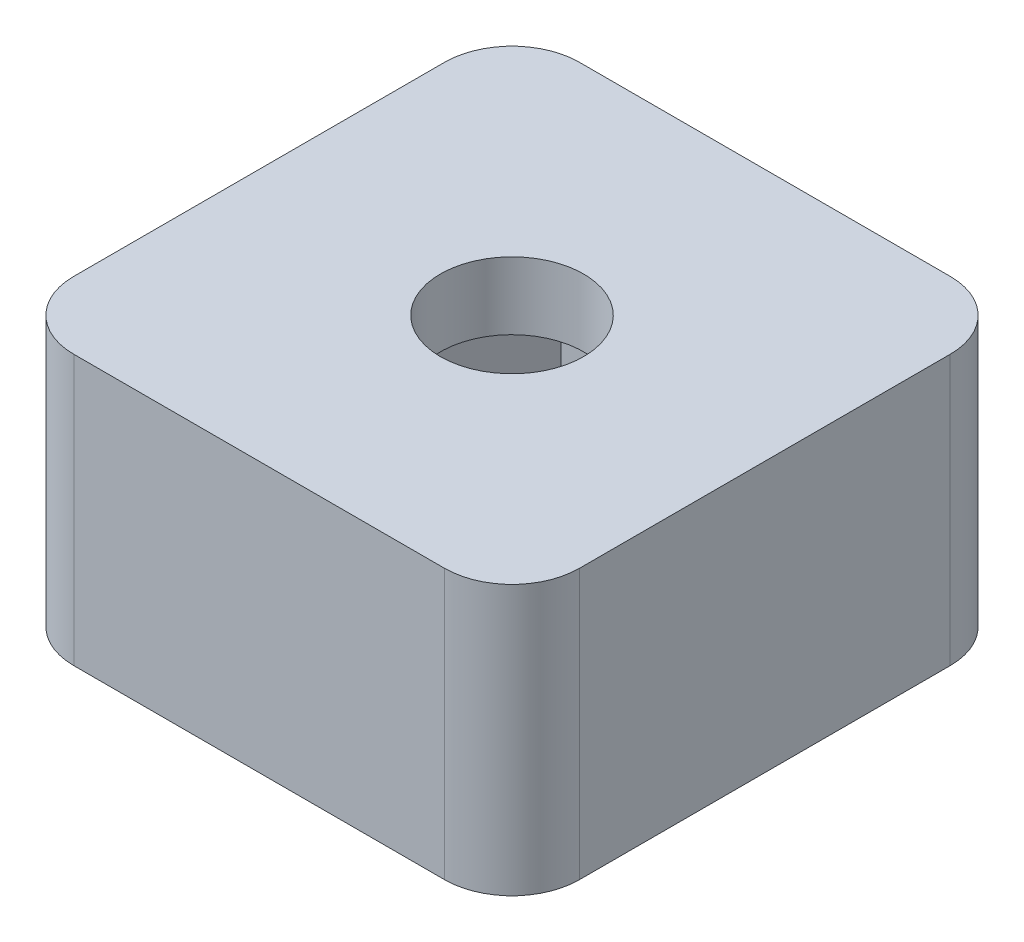
from build123d import *

# Parameters (mm, degrees)
SKETCH1_W           = 15
SKETCH1_H           = 15
BOSS_EXTRUDE1_DEPTH = 8
SKETCH3_R           = 2.125
CUT_EXTRUDE3_DEPTH  = 9
CUT_EXTRUDE2_DEPTH  = 6
FILLET1_R           = 2


with BuildPart() as part:
    # Sketch1 → Boss-Extrude1 (new body)
    with BuildSketch(Plane(origin=(0, 0, 0), x_dir=(1, 0, 0), z_dir=(0, 1, 0))):
        with Locations((7.5, 7.5)):
            Rectangle(SKETCH1_W, SKETCH1_H)
    extrude(amount=BOSS_EXTRUDE1_DEPTH)

    # Sketch3 → Cut-Extrude3 (cut, through all)
    with BuildSketch(Plane(origin=(0, 8, 0), x_dir=(1, 0, 0), z_dir=(0, 1, 0))):
        with Locations((7.5, 7.5)):
            Circle(SKETCH3_R)
    extrude(amount=-CUT_EXTRUDE3_DEPTH, mode=Mode.SUBTRACT)

    # Sketch2 → Cut-Extrude2 (cut)
    with BuildSketch(Plane(origin=(0, 0, 0), x_dir=(1, 0, 0), z_dir=(0, 1, 0))):
        Polygon((11.483716857, 7.5), (9.491858429, 10.95), (5.508141571, 10.95), (3.516283143, 7.5), (5.508141571, 4.05), (9.491858429, 4.05), align=None)
    extrude(amount=CUT_EXTRUDE2_DEPTH, mode=Mode.SUBTRACT)

    # Fillet1
    fillet1_edges = [part.edges().sort_by_distance(p)[0] for p in [
        (0, 4, -15),
        (15, 4, -15),
        (15, 4, 0),
        (0, 4, 0),
    ]]
    fillet(fillet1_edges, radius=FILLET1_R)


solid = part.part
